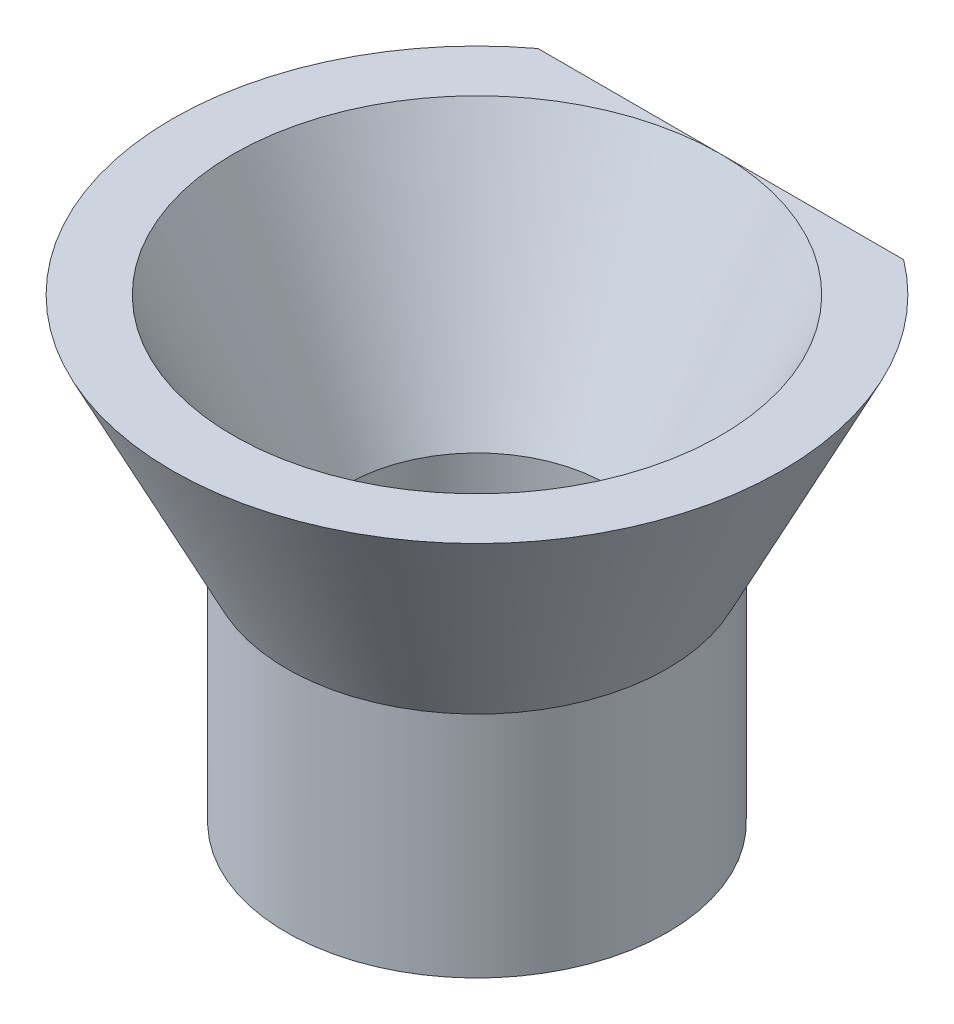
from build123d import *

# Parameters (mm, degrees)
CROQUIS3_R              = 6.25
CROQUIS3_R_2            = 4.25
SALIENTE_EXTRUIR1_DEPTH = 7.5
CORTAR_EXTRUIR1_DEPTH   = 10


with BuildPart() as part:
    # Croquis2 → Revolución1 (revolve)
    with BuildSketch(Plane.XY):
        Polygon((-4.25, 0), (-8, 7.5), (-10, 7.5), (-6.25, 0), align=None)
    revolve(axis=Axis((0, 7.5, 0), (0, -1, 0)))

    # Croquis3 → Saliente-Extruir1 (add)
    with BuildSketch(Plane.XZ):
        Circle(CROQUIS3_R)
        Circle(CROQUIS3_R_2, mode=Mode.SUBTRACT)
    extrude(amount=SALIENTE_EXTRUIR1_DEPTH)

    # Croquis4 → Cortar-Extruir1 (cut)
    with BuildSketch(Plane(origin=(0, 7.5, 0), x_dir=(1, 0, 0), z_dir=(0, 1, 0))):
        Polygon((-7.816541924, 8), (7.816541924, 8), (0, 11.458627945), align=None)
    extrude(amount=-CORTAR_EXTRUIR1_DEPTH, mode=Mode.SUBTRACT)


solid = part.part
